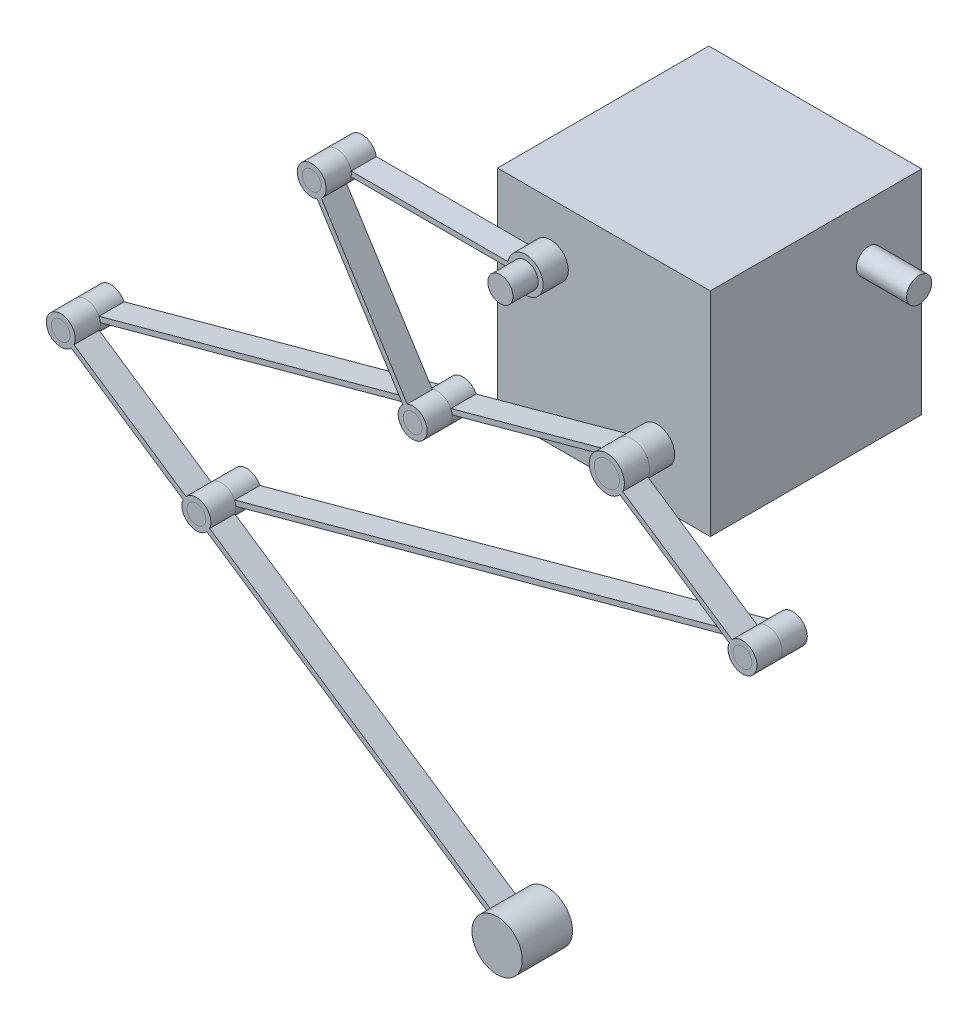
from build123d import *

# Parameters (mm, degrees)
SKETCH1_R                  = 5
BOSS_EXTRUDE1_DEPTH        = 10
BOSS_EXTRUDE1_DEPTH_BACK   = 10
BOSS_EXTRUDE1_2_DEPTH      = 10
BOSS_EXTRUDE1_2_DEPTH_BACK = 10
SKETCH1_R_2                = 3.75
BOSS_EXTRUDE1_3_DEPTH      = 10
BOSS_EXTRUDE1_3_DEPTH_BACK = 10
BOSS_EXTRUDE1_4_DEPTH      = 10
BOSS_EXTRUDE1_4_DEPTH_BACK = 10
BOSS_EXTRUDE1_5_DEPTH      = 10
BOSS_EXTRUDE1_5_DEPTH_BACK = 10
BOSS_EXTRUDE1_6_DEPTH      = 10
BOSS_EXTRUDE1_6_DEPTH_BACK = 10
BOSS_EXTRUDE1_7_DEPTH      = 10
BOSS_EXTRUDE1_7_DEPTH_BACK = 10
BOSS_EXTRUDE2_DEPTH        = 10
BOSS_EXTRUDE2_2_DEPTH      = 10
BOSS_EXTRUDE2_3_DEPTH      = 10
BOSS_EXTRUDE2_4_DEPTH      = 10
BOSS_EXTRUDE3_DEPTH        = 10
BOSS_EXTRUDE3_2_DEPTH      = 10
BOSS_EXTRUDE3_3_DEPTH      = 10
BOSS_EXTRUDE3_4_DEPTH      = 10
SKETCH5_W                  = 84.6
SKETCH5_H                  = 84.6
BOSS_EXTRUDE4_DEPTH        = 84
SKETCH6_R                  = 5
BOSS_EXTRUDE5_DEPTH        = 20
SKETCH7_R                  = 5.75
SKETCH7_R_2                = 3.75
SKETCH7_R_3                = 7
SKETCH7_R_4                = 5
BOSS_EXTRUDE6_DEPTH        = 10
BOSS_EXTRUDE7_DEPTH        = 10
SKETCH9_R                  = 5.75
SKETCH9_R_2                = 3.75
SKETCH9_R_3                = 7
SKETCH9_R_4                = 5
BOSS_EXTRUDE8_DEPTH        = 10
SKETCH10_R                 = 3.75
SKETCH10_R_2               = 5.75
BOSS_EXTRUDE9_DEPTH        = 10
SKETCH12_R                 = 7
SKETCH12_R_2               = 5
SKETCH12_R_3               = 5.75
SKETCH12_R_4               = 3.75
BOSS_EXTRUDE10_DEPTH       = 10
SKETCH13_R                 = 5.75
SKETCH13_R_2               = 3.75
BOSS_EXTRUDE11_DEPTH       = 10
SKETCH14_R                 = 10
BOSS_EXTRUDE12_DEPTH       = 5
BOSS_EXTRUDE12_DEPTH_BACK  = 15


with BuildPart() as part:
    # Sketch1 → Boss-Extrude1 (new body, two sides)
    with BuildSketch(Plane.XY) as boss_extrude1_sk:
        Circle(SKETCH1_R)
    extrude(amount=BOSS_EXTRUDE1_DEPTH)
    extrude(boss_extrude1_sk.sketch, amount=-BOSS_EXTRUDE1_DEPTH_BACK)


with BuildPart() as body_2:
    # Sketch1 → Boss-Extrude1 2 (new body, two sides)
    with BuildSketch(Plane.XY) as boss_extrude1_2_sk:
        with Locations((-42.3, 42.3)):
            Circle(SKETCH1_R)
    extrude(amount=BOSS_EXTRUDE1_2_DEPTH)
    extrude(boss_extrude1_2_sk.sketch, amount=-BOSS_EXTRUDE1_2_DEPTH_BACK)


    add(part.part)  # Boss-Extrude4 merges part
    # Sketch5 → Boss-Extrude4 (add)
    with BuildSketch(Plane(origin=(0, 0, -10), x_dir=(-1, 0, 0), z_dir=(0, 0, -1))):
        with Locations((21.15, 21.15)):
            Rectangle(SKETCH5_W, SKETCH5_H)
    extrude(amount=BOSS_EXTRUDE4_DEPTH)

    # Sketch6 → Boss-Extrude5 (add)
    with BuildSketch(Plane(origin=(21.15, 0, 0), x_dir=(0, 0, -1), z_dir=(1, 0, 0))):
        with Locations((73.000229017, 42.321464623)):
            Circle(SKETCH6_R)
    extrude(amount=BOSS_EXTRUDE5_DEPTH)


with BuildPart() as body_3:
    # Sketch1 → Boss-Extrude1 3 (new body, two sides)
    with BuildSketch(Plane.XY) as boss_extrude1_3_sk:
        with Locations((-117.3, 42.3)):
            Circle(SKETCH1_R_2)
    extrude(amount=BOSS_EXTRUDE1_3_DEPTH)
    extrude(boss_extrude1_3_sk.sketch, amount=-BOSS_EXTRUDE1_3_DEPTH_BACK)


with BuildPart() as body_4:
    # Sketch1 → Boss-Extrude1 4 (new body, two sides)
    with BuildSketch(Plane.XY) as boss_extrude1_4_sk:
        with Locations((53.933597832, -36.279016316)):
            Circle(SKETCH1_R_2)
    extrude(amount=BOSS_EXTRUDE1_4_DEPTH)
    extrude(boss_extrude1_4_sk.sketch, amount=-BOSS_EXTRUDE1_4_DEPTH_BACK)


with BuildPart() as body_5:
    # Sketch1 → Boss-Extrude1 5 (new body, two sides)
    with BuildSketch(Plane.XY) as boss_extrude1_5_sk:
        with Locations((-77.176830051, -21.065063191)):
            Circle(SKETCH1_R_2)
    extrude(amount=BOSS_EXTRUDE1_5_DEPTH)
    extrude(boss_extrude1_5_sk.sketch, amount=-BOSS_EXTRUDE1_5_DEPTH_BACK)


with BuildPart() as body_6:
    # Sketch1 → Boss-Extrude1 6 (new body, two sides)
    with BuildSketch(Plane.XY) as boss_extrude1_6_sk:
        with Locations((-163.126236958, -95.524506616)):
            Circle(SKETCH1_R_2)
    extrude(amount=BOSS_EXTRUDE1_6_DEPTH)
    extrude(boss_extrude1_6_sk.sketch, amount=-BOSS_EXTRUDE1_6_DEPTH_BACK)


with BuildPart() as body_7:
    # Sketch1 → Boss-Extrude1 7 (new body, two sides)
    with BuildSketch(Plane.XY) as boss_extrude1_7_sk:
        with Locations((-217.05983479, -59.2454903)):
            Circle(SKETCH1_R_2)
    extrude(amount=BOSS_EXTRUDE1_7_DEPTH)
    extrude(boss_extrude1_7_sk.sketch, amount=-BOSS_EXTRUDE1_7_DEPTH_BACK)


with BuildPart() as body_8:
    # Sketch2 → Boss-Extrude2 (new body)
    with BuildSketch(Plane.XY):
        with BuildLine():
            Line((-79.955210691, -18.546511818), (-116.211354379, 38.711497428))
            ThreePointArc((-116.211354379, 38.711497428), (-115.293841503, 39.13174684), (-114.52161936, 39.781448626))
            Line((-114.52161936, 39.781448626), (-78.265475672, -17.476560619))
            ThreePointArc((-78.265475672, -17.476560619), (-79.182988549, -17.896810032), (-79.955210691, -18.546511818))
        make_face()
    extrude(amount=BOSS_EXTRUDE2_DEPTH)

    # Sketch8 → Boss-Extrude7 (add)
    with BuildSketch(Plane.XY.offset(10)):
        with BuildLine():
            ThreePointArc((-116.211354379, 38.711497428), (-120.312052546, 44.533839623), (-113.55, 42.3))
            ThreePointArc((-113.55, 42.3), (-113.801326866, 40.950264359), (-114.52161936, 39.781448626))
            Line((-114.52161936, 39.781448626), (-113.425899589, 38.051018239))
            ThreePointArc((-113.425899589, 38.051018239), (-112.262633091, 39.527377663), (-111.637624174, 41.3))
            ThreePointArc((-111.637624174, 41.3), (-111.571947931, 41.798084171), (-111.55, 42.3))
            ThreePointArc((-111.55, 42.3), (-111.571947931, 42.801915829), (-111.637624174, 43.3))
            ThreePointArc((-111.637624174, 43.3), (-122.337366909, 45.072622337), (-115.115634608, 36.98106704))
            Line((-115.115634608, 36.98106704), (-116.211354379, 38.711497428))
        make_face()
        with BuildLine():
            ThreePointArc((-114.52161936, 39.781448626), (-115.293841503, 39.13174684), (-116.211354379, 38.711497428))
            Line((-116.211354379, 38.711497428), (-115.115634608, 36.98106704))
            ThreePointArc((-115.115634608, 36.98106704), (-114.223890304, 37.442011822), (-113.425899589, 38.051018239))
            Line((-113.425899589, 38.051018239), (-114.52161936, 39.781448626))
        make_face()
        with BuildLine():
            Line((-79.955210691, -18.546511818), (-81.050930462, -16.81608143))
            ThreePointArc((-81.050930462, -16.81608143), (-79.499158908, -26.32522371), (-71.426830051, -21.065063191))
            ThreePointArc((-71.426830051, -21.065063191), (-73.975080608, -16.288945469), (-79.361195443, -15.746130231))
            Line((-79.361195443, -15.746130231), (-78.265475672, -17.476560619))
            ThreePointArc((-78.265475672, -17.476560619), (-74.942990428, -18.053010645), (-73.426830051, -21.065063191))
            ThreePointArc((-73.426830051, -21.065063191), (-78.526565692, -24.563736326), (-79.955210691, -18.546511818))
        make_face()
        with BuildLine():
            ThreePointArc((-79.361195443, -15.746130231), (-80.252939747, -16.207075013), (-81.050930462, -16.81608143))
            Line((-81.050930462, -16.81608143), (-79.955210691, -18.546511818))
            ThreePointArc((-79.955210691, -18.546511818), (-79.182988549, -17.896810032), (-78.265475672, -17.476560619))
            Line((-78.265475672, -17.476560619), (-79.361195443, -15.746130231))
        make_face()
    extrude(amount=-BOSS_EXTRUDE7_DEPTH)


with BuildPart() as body_9:
    # Sketch2 → Boss-Extrude2 2 (new body)
    with BuildSketch(Plane.XY):
        with BuildLine():
            Line((-30.924750237, -185.656448284), (-29.808472812, -183.996952966))
            Line((-29.808472812, -183.996952966), (-159.569217557, -96.711988398))
            ThreePointArc((-159.569217557, -96.711988398), (-160.014683237, -97.617526788), (-160.685494982, -98.371483716))
            Line((-160.685494982, -98.371483716), (-30.924750237, -185.656448284))
        make_face()
    extrude(amount=BOSS_EXTRUDE2_2_DEPTH)


with BuildPart() as body_10:
    # Sketch2 → Boss-Extrude2 3 (new body)
    with BuildSketch(Plane.XY):
        with BuildLine():
            Line((4.623055472, -1.904562444), (51.492855857, -33.432039216))
            ThreePointArc((51.492855857, -33.432039216), (50.822044111, -34.185996144), (50.376578432, -35.091534534))
            Line((50.376578432, -35.091534534), (3.506778047, -3.564057762))
            ThreePointArc((3.506778047, -3.564057762), (4.148738295, -2.790693563), (4.623055472, -1.904562444))
        make_face()
    extrude(amount=BOSS_EXTRUDE2_3_DEPTH)

    # Sketch12 → Boss-Extrude10 (add)
    with BuildSketch(Plane.XY.offset(10)):
        Circle(SKETCH12_R)
        Circle(SKETCH12_R_2, mode=Mode.SUBTRACT)
        with Locations((53.933597832, -36.279016316)):
            Circle(SKETCH12_R_3)
        with Locations((53.933597832, -36.279016316)):
            Circle(SKETCH12_R_4, mode=Mode.SUBTRACT)
    extrude(amount=-BOSS_EXTRUDE10_DEPTH)


with BuildPart() as body_11:
    # Sketch2 → Boss-Extrude2 4 (new body)
    with BuildSketch(Plane.XY):
        with BuildLine():
            Line((-214.619092815, -62.0924674), (-166.683256358, -94.337024834))
            ThreePointArc((-166.683256358, -94.337024834), (-166.237790679, -93.431486444), (-165.566978933, -92.677529516))
            Line((-165.566978933, -92.677529516), (-213.502815389, -60.432972082))
            ThreePointArc((-213.502815389, -60.432972082), (-213.948281069, -61.338510472), (-214.619092815, -62.0924674))
        make_face()
    extrude(amount=BOSS_EXTRUDE2_4_DEPTH)


    add(body_9.part)  # Boss-Extrude9 merges body 9
    # Sketch10 → Boss-Extrude9 (add)
    with BuildSketch(Plane.XY.offset(10)):
        with BuildLine():
            ThreePointArc((-211.333968783, -58.719221867), (-211.512750123, -57.731438881), (-211.860595363, -56.789801114))
            ThreePointArc((-211.860595363, -56.789801114), (-222.670455376, -60.503837091), (-211.30983479, -59.2454903))
            ThreePointArc((-211.30983479, -59.2454903), (-211.315871457, -58.982079541), (-211.333968783, -58.719221867))
        make_face()
        with Locations((-217.05983479, -59.2454903)):
            Circle(SKETCH10_R, mode=Mode.SUBTRACT)
        with Locations((-163.126236958, -95.524506616)):
            Circle(SKETCH10_R_2)
        with Locations((-163.126236958, -95.524506616)):
            Circle(SKETCH10_R, mode=Mode.SUBTRACT)
    extrude(amount=-BOSS_EXTRUDE9_DEPTH)

    # Sketch14 → Boss-Extrude12 (add, two sides)
    with BuildSketch(Plane.XY.offset(10)) as boss_extrude12_sk:
        with Locations((-38.622496491, -179.273290553)):
            Circle(SKETCH14_R)
    extrude(amount=BOSS_EXTRUDE12_DEPTH)
    extrude(boss_extrude12_sk.sketch, amount=-BOSS_EXTRUDE12_DEPTH_BACK)


with BuildPart() as body_12:
    # Sketch4 → Boss-Extrude3 (new body)
    with BuildSketch(Plane.XY):
        with BuildLine():
            ThreePointArc((-47.198979486, 43.3), (-47.3, 42.3), (-47.198979486, 41.3))
            Line((-47.198979486, 41.3), (-113.685791926, 41.3))
            ThreePointArc((-113.685791926, 41.3), (-113.55, 42.3), (-113.685791926, 43.3))
            Line((-113.685791926, 43.3), (-47.198979486, 43.3))
        make_face()
    extrude(amount=-BOSS_EXTRUDE3_DEPTH)

    # Sketch7 → Boss-Extrude6 (add)
    with BuildSketch(Plane.XY):
        with Locations((-117.3, 42.3)):
            Circle(SKETCH7_R)
        with Locations((-117.3, 42.3)):
            Circle(SKETCH7_R_2, mode=Mode.SUBTRACT)
        with Locations((-42.3, 42.3)):
            Circle(SKETCH7_R_3)
        with Locations((-42.3, 42.3)):
            Circle(SKETCH7_R_4, mode=Mode.SUBTRACT)
    extrude(amount=-BOSS_EXTRUDE6_DEPTH)


with BuildPart() as body_13:
    # Sketch4 → Boss-Extrude3 2 (new body)
    with BuildSketch(Plane.XY):
        with BuildLine():
            Line((-80.926807374, -21.052021834), (-213.836484048, -57.329110904))
            ThreePointArc((-213.836484048, -57.329110904), (-213.442170877, -58.258065462), (-213.309857467, -59.258531657))
            Line((-213.309857467, -59.258531657), (-80.400180794, -22.981442588))
            ThreePointArc((-80.400180794, -22.981442588), (-80.794493964, -22.05248803), (-80.926807374, -21.052021834))
        make_face()
    extrude(amount=-BOSS_EXTRUDE3_2_DEPTH)


with BuildPart() as body_14:
    # Sketch4 → Boss-Extrude3 3 (new body)
    with BuildSketch(Plane.XY):
        with BuildLine():
            Line((-4.989409636, -0.32525603), (-73.953479309, -19.148683795))
            ThreePointArc((-73.953479309, -19.148683795), (-73.559166138, -20.077638353), (-73.426852728, -21.078104549))
            Line((-73.426852728, -21.078104549), (-4.462783055, -2.254676784))
            ThreePointArc((-4.462783055, -2.254676784), (-4.823551884, -1.316566451), (-4.989409636, -0.32525603))
        make_face()
    extrude(amount=-BOSS_EXTRUDE3_3_DEPTH)


    add(body_13.part)  # Boss-Extrude8 merges body 13
    # Sketch9 → Boss-Extrude8 (add)
    with BuildSketch(Plane.XY):
        with Locations((-77.176830051, -21.065063191)):
            Circle(SKETCH9_R)
        with Locations((-77.176830051, -21.065063191)):
            Circle(SKETCH9_R_2, mode=Mode.SUBTRACT)
        Circle(SKETCH9_R_3)
        Circle(SKETCH9_R_4, mode=Mode.SUBTRACT)
        with Locations((-217.05983479, -59.2454903)):
            Circle(SKETCH9_R)
        with Locations((-217.05983479, -59.2454903)):
            Circle(SKETCH9_R_2, mode=Mode.SUBTRACT)
    extrude(amount=-BOSS_EXTRUDE8_DEPTH)


with BuildPart() as body_15:
    # Sketch4 → Boss-Extrude3 4 (new body)
    with BuildSketch(Plane.XY):
        with BuildLine():
            Line((-159.376259635, -95.537547973), (50.71024709, -38.195395712))
            ThreePointArc((50.71024709, -38.195395712), (50.315933919, -37.266441154), (50.183620509, -36.265974959))
            Line((50.183620509, -36.265974959), (-159.902886215, -93.60812722))
            ThreePointArc((-159.902886215, -93.60812722), (-159.508573045, -94.537081778), (-159.376259635, -95.537547973))
        make_face()
    extrude(amount=-BOSS_EXTRUDE3_4_DEPTH)

    # Sketch13 → Boss-Extrude11 (add)
    with BuildSketch(Plane(origin=(0, 0, -10), x_dir=(-1, 0, 0), z_dir=(0, 0, -1))):
        with Locations((-53.933597832, -36.279016316)):
            Circle(SKETCH13_R)
        with Locations((-53.933597832, -36.279016316)):
            Circle(SKETCH13_R_2, mode=Mode.SUBTRACT)
        with Locations((163.126236958, -95.524506616)):
            Circle(SKETCH13_R)
        with Locations((163.126236958, -95.524506616)):
            Circle(SKETCH13_R_2, mode=Mode.SUBTRACT)
    extrude(amount=-BOSS_EXTRUDE11_DEPTH)


solid = Compound([body_2.part, body_3.part, body_4.part, body_5.part, body_6.part, body_7.part, body_8.part, body_10.part, body_11.part, body_12.part, body_14.part, body_15.part])
